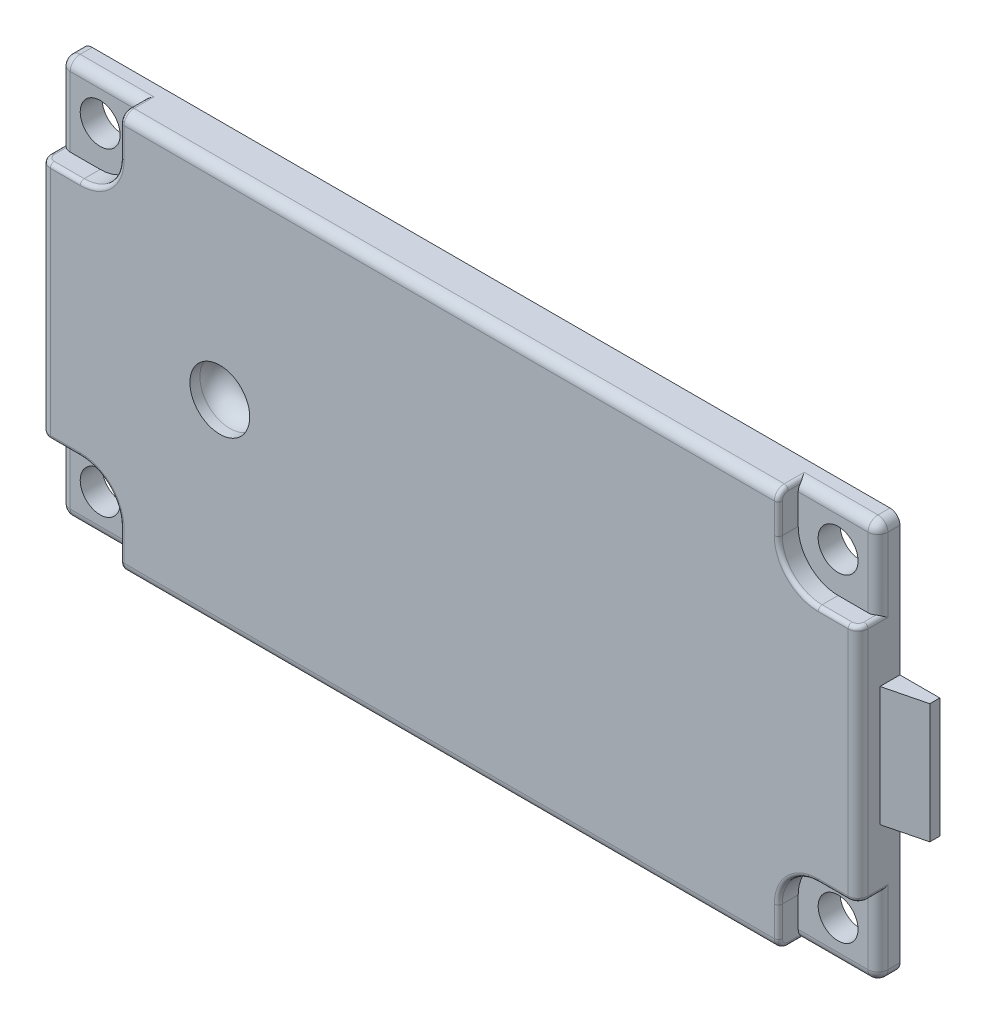
from build123d import *

# Parameters (mm, degrees)
SKETCH1_W           = 41
SKETCH1_H           = 20
SKETCH1_R           = 1
EXTRUDE1_DEPTH      = 2.1
CUT_EXTRUDE1_DEPTH  = 1
FILLET1_R           = 0.5
FILLET2_R           = 0.2
SKETCH3_R           = 1.5
CUT_EXTRUDE2_DEPTH  = 1.5
FILLET3_R           = 1
EXTRUDE2_DEPTH      = 3
EXTRUDE2_DEPTH_BACK = 3


with BuildPart() as part:
    # Sketch1 → Extrude1 (new body)
    with BuildSketch(Plane.XY):
        Rectangle(SKETCH1_W, SKETCH1_H)
        with Locations((-18.5, 7.998095583)):
            Circle(SKETCH1_R, mode=Mode.SUBTRACT)
        with Locations(Location((-18.5, -7.998095583, 0), (0, 0, 180))):  # turned: the seam where the file's is
            Circle(SKETCH1_R, mode=Mode.SUBTRACT)
        with Locations(Location((18.5, 7.998095583, 0), (0, 0, 180))):  # turned: the seam where the file's is
            Circle(SKETCH1_R, mode=Mode.SUBTRACT)
        with Locations((18.5, -7.998095583)):
            Circle(SKETCH1_R, mode=Mode.SUBTRACT)
    extrude(amount=EXTRUDE1_DEPTH)

    # Sketch2 → Cut-Extrude1 (cut)
    with BuildSketch(Plane.XY.offset(2.1)):
        with BuildLine():
            Line((20.5, 10), (16.5, 10))
            Line((16.5, 10), (16.5, 8))
            ThreePointArc((16.5, 8), (17.085786438, 6.585786438), (18.5, 6))
            Line((18.5, 6), (20.5, 6))
            Line((20.5, 6), (20.5, 10))
        make_face()
        with BuildLine():
            Line((16.5, -10), (16.5, -8))
            ThreePointArc((16.5, -8), (17.085786438, -6.585786438), (18.5, -6))
            Line((18.5, -6), (20.5, -6))
            Line((20.5, -6), (20.5, -10))
            Line((20.5, -10), (16.5, -10))
        make_face()
        with BuildLine():
            Line((-20.5, -10), (-16.5, -10))
            Line((-16.5, -10), (-16.5, -8))
            ThreePointArc((-16.5, -8), (-17.085786438, -6.585786438), (-18.5, -6))
            Line((-18.5, -6), (-20.5, -6))
            Line((-20.5, -6), (-20.5, -10))
        make_face()
        with BuildLine():
            Line((-16.5, 10), (-16.5, 8))
            ThreePointArc((-16.5, 8), (-17.085786438, 6.585786438), (-18.5, 6))
            Line((-18.5, 6), (-20.5, 6))
            Line((-20.5, 6), (-20.5, 10))
            Line((-20.5, 10), (-16.5, 10))
        make_face()
    extrude(amount=-CUT_EXTRUDE1_DEPTH, mode=Mode.SUBTRACT)

    # Fillet1
    fillet1_edges = [part.edges().sort_by_distance(p)[0] for p in [
        (0, 10, 2.1),
        (20.5, 10, 0.55),
        (20.5, 8, 1.1),
        (18.5, 10, 1.1),
        (20.5, 0, 2.1),
        (20.5, -10, 0.55),
        (20.5, -8, 1.1),
        (18.5, -10, 1.1),
        (0, -10, 2.1),
        (-20.5, -10, 0.55),
        (-18.5, -10, 1.1),
        (-20.5, -8, 1.1),
        (-20.5, 10, 0.55),
        (-20.5, 0, 2.1),
        (-20.5, 8, 1.1),
        (-18.5, 10, 1.1),
    ]]
    fillet(fillet1_edges, radius=FILLET1_R)

    # Fillet2
    fillet2_edges = [part.edges().sort_by_distance(p)[0] for p in [
        (-19.25, 6, 2.1),
        (-16.5, -8.75, 2.1),
        (19.25, -6, 2.1),
        (16.5, 8.75, 2.1),
        (20.353553391, 6, 1.953553391),
        (20.353553391, -6, 1.953553391),
        (-20.353553391, -6, 1.953553391),
        (-20.353553391, 6, 1.953553391),
        (16.5, -9.853553391, 1.953553391),
        (-16.5, -9.853553391, 1.953553391),
        (-16.5, 9.853553391, 1.953553391),
        (16.5, 9.853553391, 1.953553391),
        (20.5, 6, 1.35),
        (16.5, 10, 1.35),
        (17.085786438, 6.585786438, 2.1),
        (19.25, 6, 2.1),
        (20.5, -6, 0.85),
        (16.5, -10, 1.35),
        (17.085786438, -6.585786438, 2.1),
        (16.5, -8.75, 2.1),
        (-16.5, -10, 0.85),
        (-20.5, -6, 0.85),
        (-17.085786438, -6.585786438, 2.1),
        (-19.25, -6, 2.1),
        (-20.5, 6, 0.85),
        (-16.5, 10, 1.35),
        (-17.085786438, 6.585786438, 2.1),
        (-16.5, 8.75, 2.1),
    ]]
    fillet(fillet2_edges, radius=FILLET2_R)

    # Sketch3 → Cut-Extrude2 (cut)
    with BuildSketch(Plane.XY.offset(2.1)):
        with Locations((-11.5, 0)):
            Circle(SKETCH3_R)
    extrude(amount=-CUT_EXTRUDE2_DEPTH, mode=Mode.SUBTRACT)

    # Fillet3
    fillet3_edges = [part.edges().sort_by_distance(p)[0] for p in [
        (-13, 0, 0.6),
    ]]
    fillet(fillet3_edges, radius=FILLET3_R)

    # Sketch4 → Extrude2 (add, two sides)
    with BuildSketch(Plane(origin=(0, 0, 0), x_dir=(1, 0, 0), z_dir=(0, 1, 0))) as extrude2_sk:
        Polygon((20.5, 0), (22.5, 0), (22.5, -0.5), (20.5, -1), align=None)
    extrude(amount=EXTRUDE2_DEPTH)
    extrude(extrude2_sk.sketch, amount=-EXTRUDE2_DEPTH_BACK)


solid = part.part
